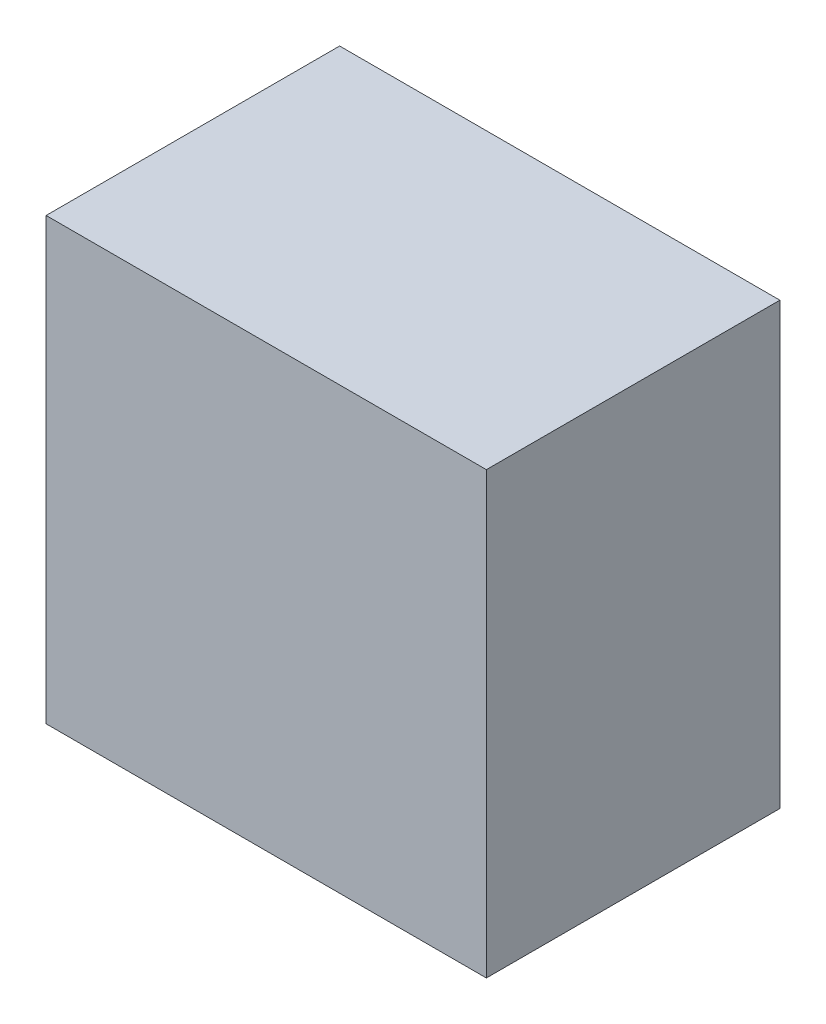
from build123d import *

# Parameters (mm, degrees)
SKETCH_1_W      = 30
SKETCH_1_H      = 30
EXTRUDE_1_DEPTH = 20


with BuildPart() as part:
    # 草图1 → 凸台-拉伸1 (new body)
    with BuildSketch(Plane.XY):
        Rectangle(SKETCH_1_W, SKETCH_1_H)
    extrude(amount=EXTRUDE_1_DEPTH)


solid = part.part
